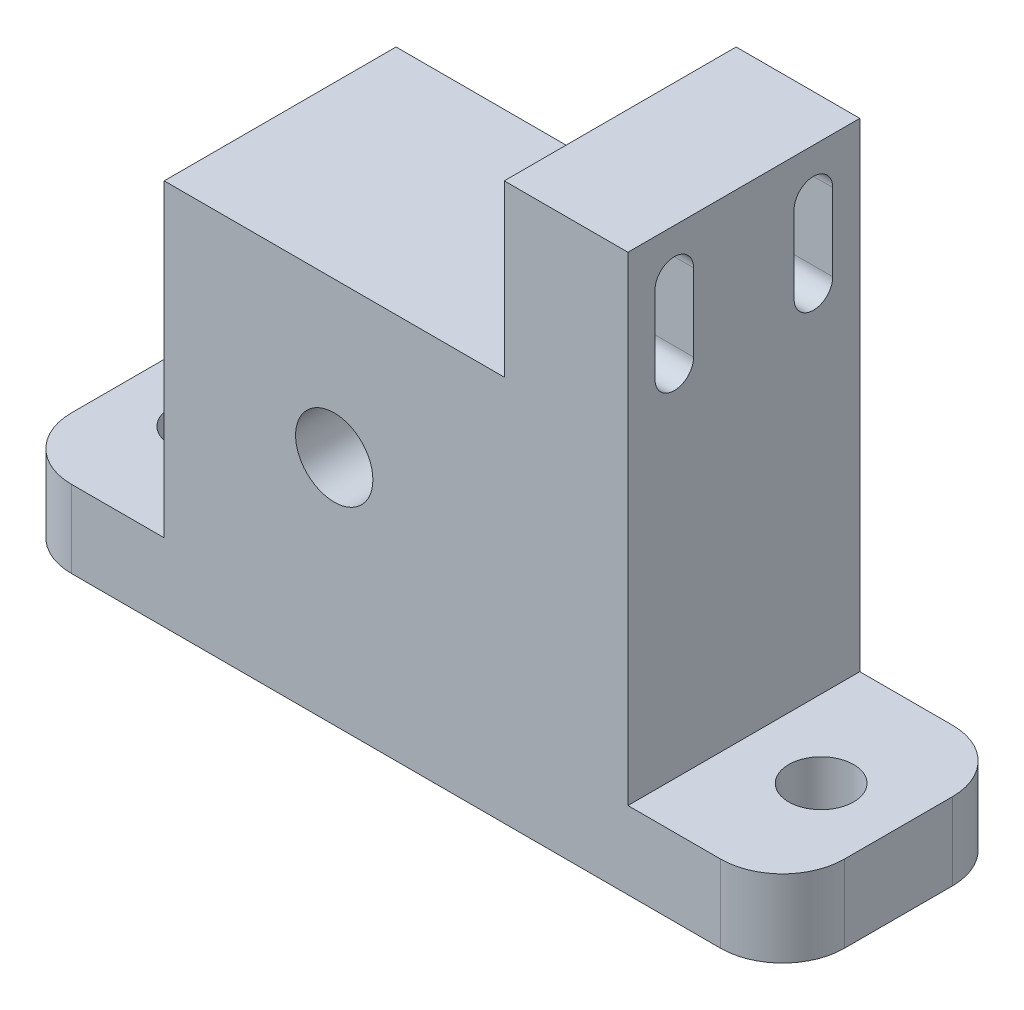
from build123d import *

# Parameters (mm, degrees)
ESQUISSE2_W             = 30
ESQUISSE2_H             = 15
BOSS_EXTRU_1_DEPTH      = 25
ESQUISSE3_W             = 8
ESQUISSE3_H             = 15
BOSS_EXTRU_2_DEPTH      = 11
ENL_V_MAT_EXTRU_1_REACH = 17
ESQUISSE4_R             = 2.5
ENL_V_MAT_EXTRU_2_REACH = 10
ESQUISSE7_W             = 50
ESQUISSE7_H             = 15
ESQUISSE7_R             = 2.1
BOSS_EXTRU_4_DEPTH      = 5
CONG_2_R                = 4


with BuildPart() as part:
    # Esquisse2 → Boss.-Extru.1 (new body)
    with BuildSketch(Plane(origin=(0, 0, 0), x_dir=(1, 0, 0), z_dir=(0, 1, 0))):
        Rectangle(ESQUISSE2_W, ESQUISSE2_H)
    extrude(amount=BOSS_EXTRU_1_DEPTH)

    # Esquisse3 → Boss.-Extru.2 (add)
    with BuildSketch(Plane(origin=(0, 25, 0), x_dir=(1, 0, 0), z_dir=(0, 1, 0))):
        with Locations((11, 0)):
            Rectangle(ESQUISSE3_W, ESQUISSE3_H)
    extrude(amount=BOSS_EXTRU_2_DEPTH)

    # Esquisse4 → Enlèv. mat.-Extru.1 (cut, up to next)
    with BuildSketch(Plane.XY.offset(7.5), mode=Mode.PRIVATE) as enl_v_mat_extru_1_sk1:
        with Locations((-4, 15)):
            Circle(ESQUISSE4_R)
    enl_v_mat_extru_1_tool1 = extrude(enl_v_mat_extru_1_sk1.sketch, amount=-ENL_V_MAT_EXTRU_1_REACH, mode=Mode.PRIVATE) & part.part
    add(enl_v_mat_extru_1_tool1.solids().sort_by_distance((-4, 15, 7.5))[0], mode=Mode.SUBTRACT)

    # Esquisse5 → Enlèv. mat.-Extru.2 (cut, up to next)
    with BuildSketch(Plane.ZY.offset(-7), mode=Mode.PRIVATE) as enl_v_mat_extru_2_sk1:
        with BuildLine():
            Line((5.75, 33), (5.75, 28))
            ThreePointArc((5.75, 28), (4.5, 26.75), (3.25, 28))
            Line((3.25, 28), (3.25, 33))
            ThreePointArc((3.25, 33), (4.5, 34.25), (5.75, 33))
        make_face()
    enl_v_mat_extru_2_tool1 = extrude(enl_v_mat_extru_2_sk1.sketch, amount=-ENL_V_MAT_EXTRU_2_REACH, mode=Mode.PRIVATE) & part.part
    add(enl_v_mat_extru_2_tool1.solids().sort_by_distance((7, 30.5, 4.5))[0], mode=Mode.SUBTRACT)
    # Esquisse5 → Enlèv. mat.-Extru.2 (cut, up to next)
    with BuildSketch(Plane.ZY.offset(-7), mode=Mode.PRIVATE) as enl_v_mat_extru_2_sk2:
        with BuildLine():
            Line((-3.25, 33), (-3.25, 28))
            ThreePointArc((-3.25, 28), (-4.5, 26.75), (-5.75, 28))
            Line((-5.75, 28), (-5.75, 33))
            ThreePointArc((-5.75, 33), (-4.5, 34.25), (-3.25, 33))
        make_face()
    enl_v_mat_extru_2_tool2 = extrude(enl_v_mat_extru_2_sk2.sketch, amount=-ENL_V_MAT_EXTRU_2_REACH, mode=Mode.PRIVATE) & part.part
    add(enl_v_mat_extru_2_tool2.solids().sort_by_distance((7, 30.5, -4.5))[0], mode=Mode.SUBTRACT)

    # Esquisse7 → Boss.-Extru.4 (add)
    with BuildSketch(Plane.XZ):
        Rectangle(ESQUISSE7_W, ESQUISSE7_H)
        with Locations((20, 0)):
            Circle(ESQUISSE7_R, mode=Mode.SUBTRACT)
        with Locations((-20, 0)):
            Circle(ESQUISSE7_R, mode=Mode.SUBTRACT)
    extrude(amount=-BOSS_EXTRU_4_DEPTH)

    # Congé2
    cong_2_edges = [part.edges().sort_by_distance(p)[0] for p in [
        (25, 2.5, -7.5),
        (-25, 2.5, 7.5),
        (25, 2.5, 7.5),
        (-25, 2.5, -7.5),
    ]]
    fillet(cong_2_edges, radius=CONG_2_R)


solid = part.part
